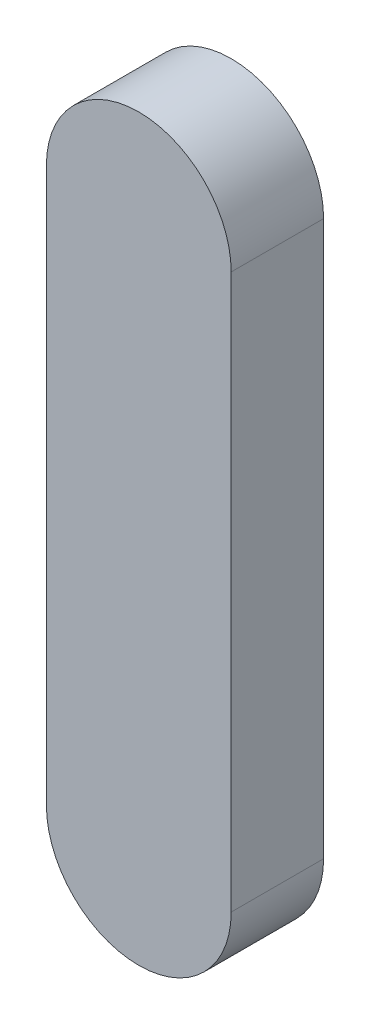
from build123d import *

# Parameters (mm, degrees)
EXTRUDE_1_DEPTH = 5


with BuildPart() as part:
    # 草图1 → 凸台-拉伸1 (new body)
    with BuildSketch(Plane.XY):
        with BuildLine():
            Line((5, 0), (5, -30))
            ThreePointArc((5, -30), (0, -35), (-5, -30))
            Line((-5, -30), (-5, 0))
            ThreePointArc((-5, 0), (0, 5), (5, 0))
        make_face()
    extrude(amount=EXTRUDE_1_DEPTH)


solid = part.part
